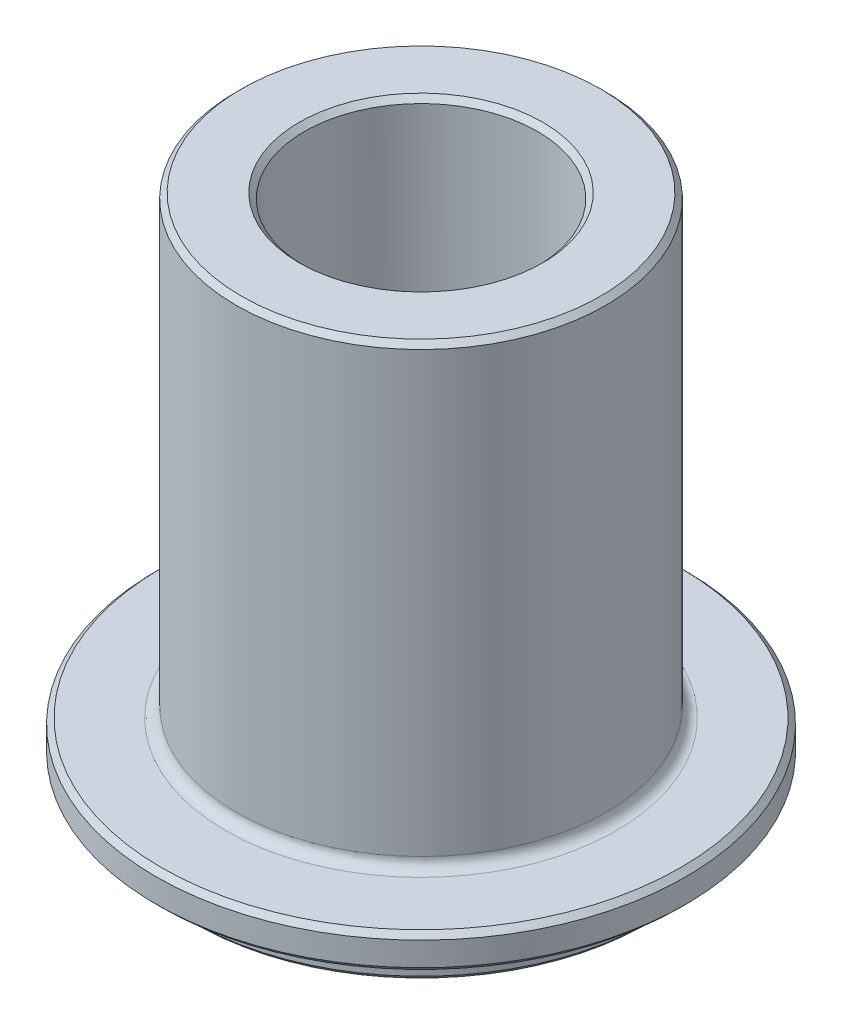
from build123d import *

# Parameters (mm, degrees)
CHAMFER1_SIZE = 0.5
FILLET1_R     = 1
CHAMFER2_SIZE = 0.5


with BuildPart() as part:
    # Sketch1 → Revolve1 (revolve)
    with BuildSketch(Plane.XY):
        Polygon((1.493038446, 27.8), (11, 33.23), (11, 49.2), (17.45, 49.2), (17.45, 6.25), (25, 6.25), (25, 3), (21.75, 3), (21.75, 0), (12.334639896, 0), (12.334639896, 25.3), (1.493038446, 25.3), align=None)
    revolve(axis=Axis((0, 0, 0), (0, 1, 0)))

    # Chamfer1
    chamfer1_edges = [part.edges().sort_by_distance(p)[0] for p in [
        (-11, 49.2, 0),
        (-17.45, 49.2, 0),
        (-25, 6.25, 0),
        (-25, 3, 0),
        (-21.75, 0, 0),
        (-12.334639896, 0, 0),
        (-1.493038446, 25.3, 0),
    ]]
    chamfer(chamfer1_edges, length=CHAMFER1_SIZE)

    # Fillet1
    fillet1_edges = [part.edges().sort_by_distance(p)[0] for p in [
        (-17.45, 6.25, 0),
    ]]
    fillet(fillet1_edges, radius=FILLET1_R)

    # Chamfer2
    chamfer2_edges = [part.edges().sort_by_distance(p)[0] for p in [
        (-12.334639896, 25.3, 0),
    ]]
    chamfer(chamfer2_edges, length=CHAMFER2_SIZE)


solid = part.part
